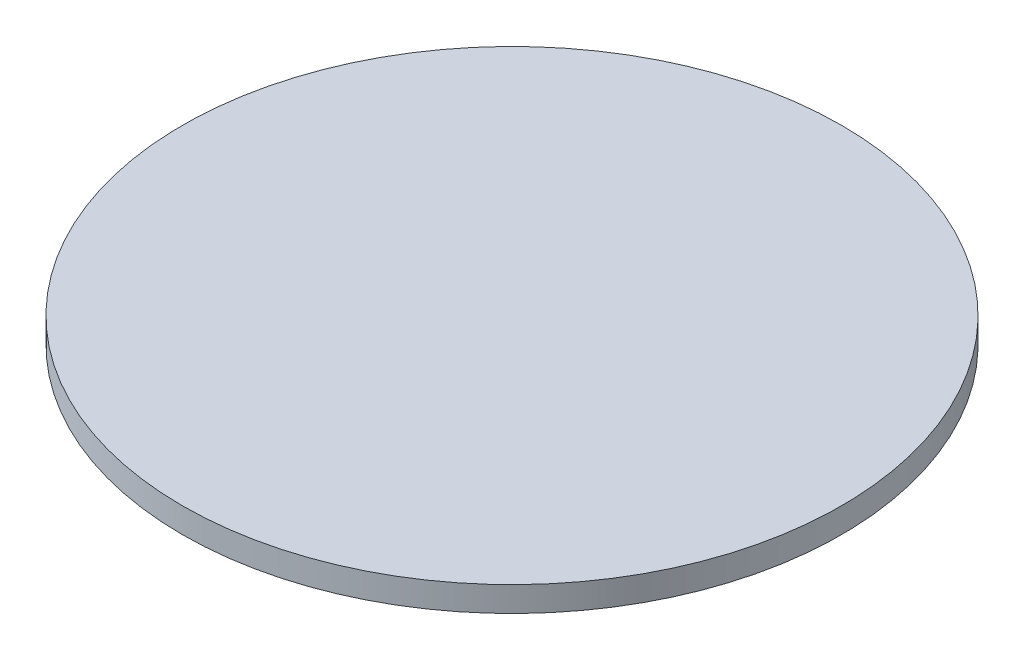
from build123d import *

# Parameters (mm, degrees)
SKETCH_1_R      = 23.7
EXTRUDE_1_DEPTH = 1.8


with BuildPart() as part:
    # 草图1 → 凸台-拉伸1 (new body)
    with BuildSketch(Plane(origin=(0, 0, 0), x_dir=(1, 0, 0), z_dir=(0, 1, 0))):
        Circle(SKETCH_1_R)
    extrude(amount=EXTRUDE_1_DEPTH)


solid = part.part
